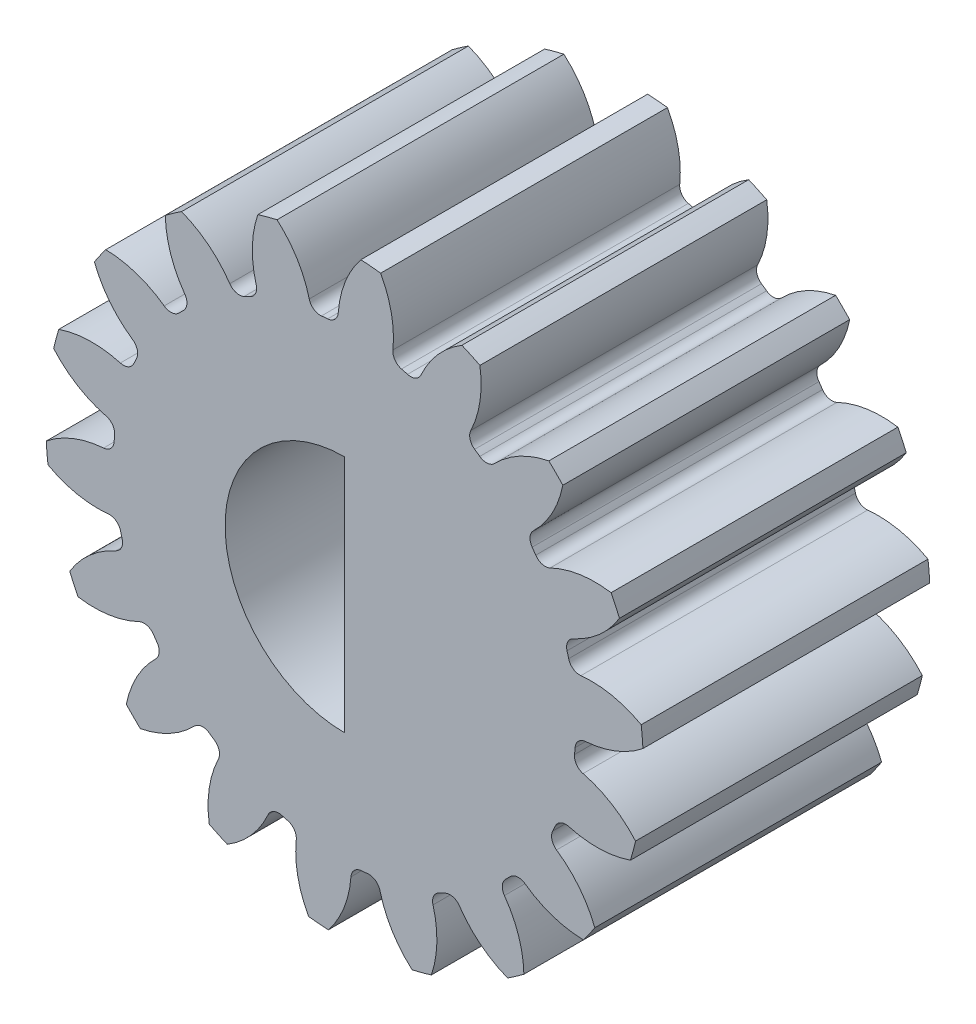
from build123d import *

# Parameters (mm, degrees)
SKETCH3_R           = 7.9375
GEARBODY_DEPTH      = 7.62
TOOTHCUT_DEPTH      = 8.62
CIRPATTERN1_COUNT   = 18
BOREDIA_R           = 3.175
BORE_DEPTH          = 12700
BOSS_EXTRUDE1_DEPTH = 3.81


with BuildPart() as part:
    # Sketch3 → gearBody (new body)
    with BuildSketch(Plane.XY):
        Circle(SKETCH3_R)
    extrude(amount=GEARBODY_DEPTH)

    # Sketch2 → toothCut (cut, through all)
    with BuildSketch(Plane.XY):
        with BuildLine():
            ThreePointArc((6.109024448, -0.620440562), (6.116845087, -0.537896263), (6.123550449, -0.45525389))
            ThreePointArc((6.123550449, -0.45525389), (6.211734547, -0.262957543), (6.404089586, -0.174901543))
            ThreePointArc((6.404089586, -0.174901543), (7.575851051, 0.185269566), (8.474852534, 1.018662927))
            ThreePointArc((8.474852534, 1.018662927), (8.503040528, -0.747730842), (8.167006715, -2.482096081))
            ThreePointArc((8.167006715, -2.482096081), (7.427249601, -1.504595405), (6.336329857, -0.945451173))
            ThreePointArc((6.336329857, -0.945451173), (6.162294814, -0.825175973), (6.109024448, -0.620440562))
        make_face()
    toothcut = extrude(amount=TOOTHCUT_DEPTH, mode=Mode.SUBTRACT)

    # CirPattern1: toothCut ×18 about axis
    cirpattern1_axis = Axis((0, 0, 0), (0, 0, 1))
    for i in range(1, CIRPATTERN1_COUNT):
        add(toothcut.rotate(cirpattern1_axis, i * 360 / CIRPATTERN1_COUNT), mode=Mode.SUBTRACT)

    # boreDia → bore (cut, symmetric)
    with BuildSketch(Plane.XY):
        Circle(BOREDIA_R)
    extrude(amount=BORE_DEPTH, both=True, mode=Mode.SUBTRACT)

    # Sketch5 → Boss-Extrude1 (add)
    with BuildSketch(Plane.XY.offset(7.62)):
        with BuildLine():
            Line((0, 3.175), (0, -3.175))
            ThreePointArc((0, -3.175), (3.175, 0), (0, 3.175))
        make_face()
    extrude(amount=-BOSS_EXTRUDE1_DEPTH)


solid = part.part
